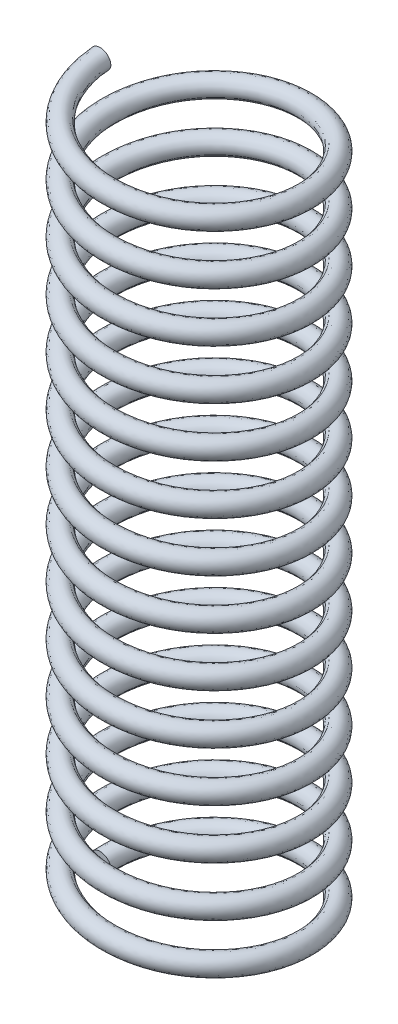
from build123d import *

# Parameters (mm, degrees)
SWEEP1_PITCH       = 1.392857143
SWEEP1_HEIGHT      = 19.5
SWEEP1_RADIUS      = 2.75
SWEEP1_START_ANGLE = -90
SWEEP1_PROFILE_R   = 0.28


with BuildPart() as part:
    # Sweep1: sweep along a helix
    with BuildLine() as sweep1_path:
        add(Helix(SWEEP1_PITCH, SWEEP1_HEIGHT, SWEEP1_RADIUS, center=(0, 0, 0), direction=(0, 1, 0), lefthand=True, mode=Mode.PRIVATE).rotate(Axis((0, 0, 0), (0, 1, 0)), SWEEP1_START_ANGLE))
    # Sweep1 profile (on start of the path) → Sweep1 (sweep)
    with BuildSketch(Plane(origin=(-2.75, 0, 0), x_dir=(0, -0.996766687, -0.080350305), z_dir=(0, 0.080350305, -0.996766687))):
        Circle(SWEEP1_PROFILE_R)
    sweep(path=sweep1_path.line, is_frenet=True)


solid = part.part
